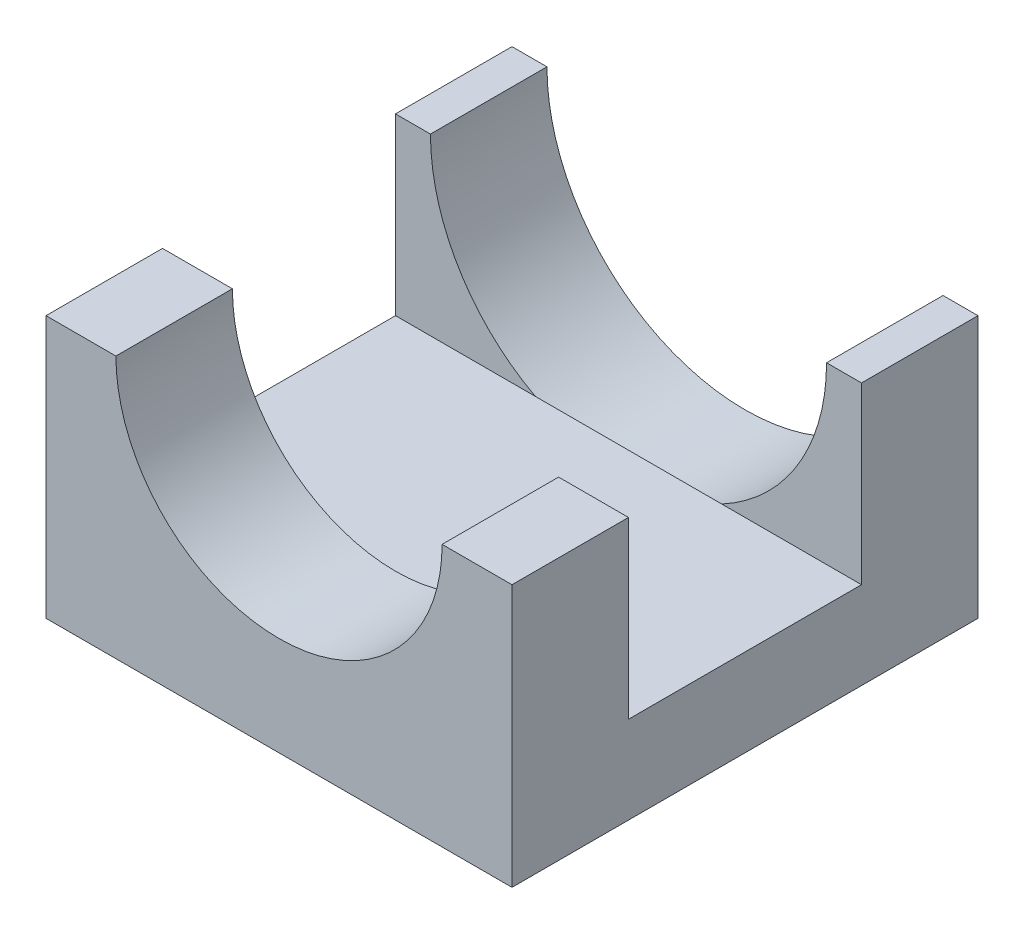
from build123d import *

# Parameters (mm, degrees)
SKETCH1_W           = 40
SKETCH1_H           = 45
BOSS_EXTRUDE1_DEPTH = 40
SKETCH2_R           = 17
CUT_EXTRUDE1_DEPTH  = 10
SKETCH3_R           = 14
CUT_EXTRUDE2_DEPTH  = 10
SKETCH4_W           = 40
SKETCH4_H           = 22.5
CUT_EXTRUDE3_DEPTH  = 51.062460986
SKETCH5_W           = 40
SKETCH5_H           = 20
CUT_EXTRUDE4_DEPTH  = 15


with BuildPart() as part:
    # Sketch1 → Boss-Extrude1 (new body)
    with BuildSketch(Plane.XY):
        Rectangle(SKETCH1_W, SKETCH1_H)
    extrude(amount=BOSS_EXTRUDE1_DEPTH)

    # Sketch2 → Cut-Extrude1 (cut)
    with BuildSketch(Plane(origin=(0, 0, 0), x_dir=(-1, 0, 0), z_dir=(0, 0, -1))):
        Circle(SKETCH2_R)
    extrude(amount=-CUT_EXTRUDE1_DEPTH, mode=Mode.SUBTRACT)

    # Sketch3 → Cut-Extrude2 (cut)
    with BuildSketch(Plane.XY.offset(40)):
        Circle(SKETCH3_R)
    extrude(amount=-CUT_EXTRUDE2_DEPTH, mode=Mode.SUBTRACT)

    # Sketch4 → Cut-Extrude3 (cut, through all)
    with BuildSketch(Plane.XY.offset(40)):
        with Locations((0, 11.25)):
            Rectangle(SKETCH4_W, SKETCH4_H)
    extrude(amount=-CUT_EXTRUDE3_DEPTH, mode=Mode.SUBTRACT)

    # Sketch5 → Cut-Extrude4 (cut)
    with BuildSketch(Plane(origin=(0, 0, 0), x_dir=(1, 0, 0), z_dir=(0, 1, 0))):
        with Locations((0, -20)):
            Rectangle(SKETCH5_W, SKETCH5_H)
    extrude(amount=-CUT_EXTRUDE4_DEPTH, mode=Mode.SUBTRACT)


solid = part.part
